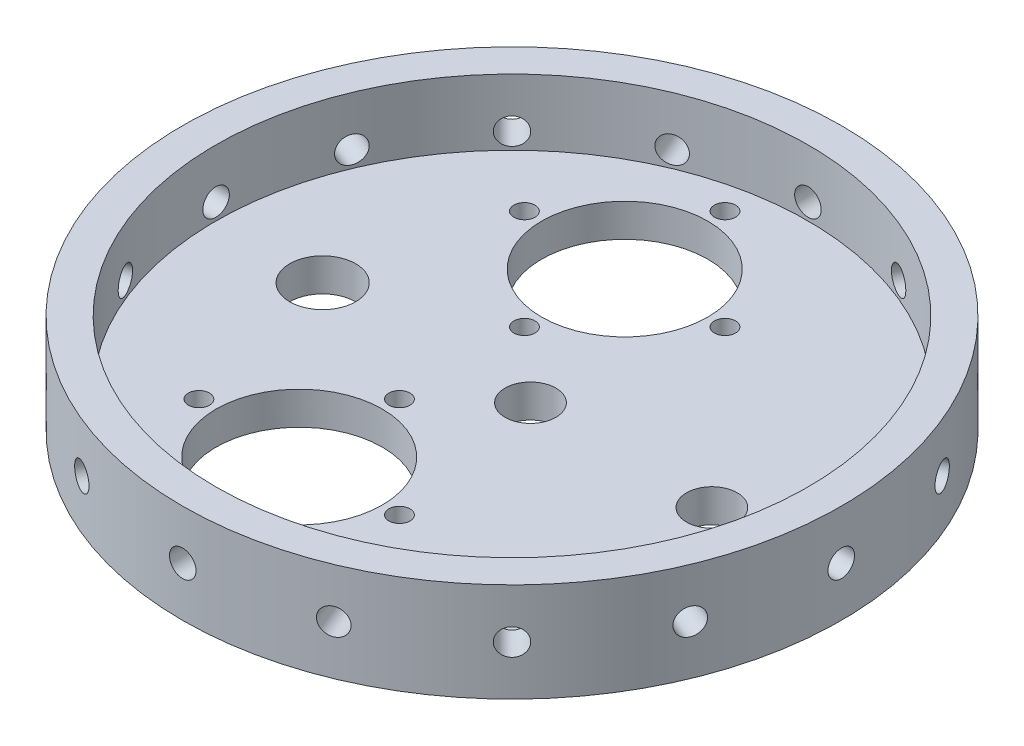
from build123d import *

# Parameters (mm, degrees)
SKETCH1_R           = 63.4365
BOSS_EXTRUDE4_DEPTH = 6.35
SKETCH25_R          = 6.35
CUT_EXTRUDE6_DEPTH  = 65.786
SKETCH32_R          = 63.4365
SKETCH32_R_2        = 57.023
BOSS_EXTRUDE3_DEPTH = 12.7
CIRPATTERN7_COUNT   = 16
SKETCH59_R          = 16.002
SKETCH59_R_2        = 2.032
CUT_EXTRUDE10_DEPTH = 80.518
SKETCH62_R          = 4.8895
CUT_EXTRUDE12_DEPTH = 80.518


with BuildPart() as part:
    # Sketch1 → Boss-Extrude4 (new body)
    with BuildSketch(Plane(origin=(0, 0, 0), x_dir=(1, 0, 0), z_dir=(0, 1, 0))):
        Circle(SKETCH1_R)
    extrude(amount=BOSS_EXTRUDE4_DEPTH)

    # Sketch25 → Cut-Extrude6 (cut)
    with BuildSketch(Plane.XZ):
        with Locations((-36.448996825, 0)):
            Circle(SKETCH25_R)
    extrude(amount=-CUT_EXTRUDE6_DEPTH, mode=Mode.SUBTRACT)

    # Sketch32 → Boss-Extrude3 (add)
    with BuildSketch(Plane(origin=(0, 6.35, 0), x_dir=(1, 0, 0), z_dir=(0, 1, 0))):
        Circle(SKETCH32_R)
        Circle(SKETCH32_R_2, mode=Mode.SUBTRACT)
    extrude(amount=BOSS_EXTRUDE3_DEPTH)

    # Sketch36 → Tap Drill for 1_4-20 Tap1 (revolve, cut)
    with BuildSketch(Plane(origin=(0, 9.525, 63.5), x_dir=(0, -1, 0), z_dir=(1, 0, 0))):
        Polygon((0, 0), (0, 11.058816902), (2.5527, 9.525), (2.5527, 0), align=None)
    tap_drill_for_1_4_20_tap1 = revolve(axis=Axis((0, 9.525, 69.85), (0, 0, -1)), mode=Mode.SUBTRACT)

    # CirPattern7: Tap Drill for 1_4-20 Tap1 ×16 about axis
    cirpattern7_axis = Axis((0, 0, 0), (0, 1, 0))
    for i in range(1, CIRPATTERN7_COUNT):
        add(tap_drill_for_1_4_20_tap1.rotate(cirpattern7_axis, i * 360 / CIRPATTERN7_COUNT), mode=Mode.SUBTRACT)

    # Sketch59 → Cut-Extrude10 (cut)
    with BuildSketch(Plane.XZ):
        with Locations((-9.652, 31.319092678)):
            Circle(SKETCH59_R)
        with Locations((-9.652, -31.348957033)):
            Circle(SKETCH59_R)
        with Locations((-9.652, 50.623092678)):
            Circle(SKETCH59_R_2)
        with Locations((9.652, 31.319092678)):
            Circle(SKETCH59_R_2)
        with Locations((-9.652, 12.015092678)):
            Circle(SKETCH59_R_2)
        with Locations((-28.956, 31.319092678)):
            Circle(SKETCH59_R_2)
        with Locations((-9.652, -12.044957033)):
            Circle(SKETCH59_R_2)
        with Locations((9.652, -31.348957033)):
            Circle(SKETCH59_R_2)
        with Locations((-9.652, -50.652957033)):
            Circle(SKETCH59_R_2)
        with Locations((-28.956, -31.348957033)):
            Circle(SKETCH59_R_2)
    extrude(amount=-CUT_EXTRUDE10_DEPTH, mode=Mode.SUBTRACT)

    # Sketch62 → Cut-Extrude12 (cut)
    with BuildSketch(Plane.XZ):
        with Locations((3.556000794, 0)):
            Circle(SKETCH62_R)
        with Locations((38.481000794, 0)):
            Circle(SKETCH62_R)
    extrude(amount=-CUT_EXTRUDE12_DEPTH, mode=Mode.SUBTRACT)


solid = part.part
